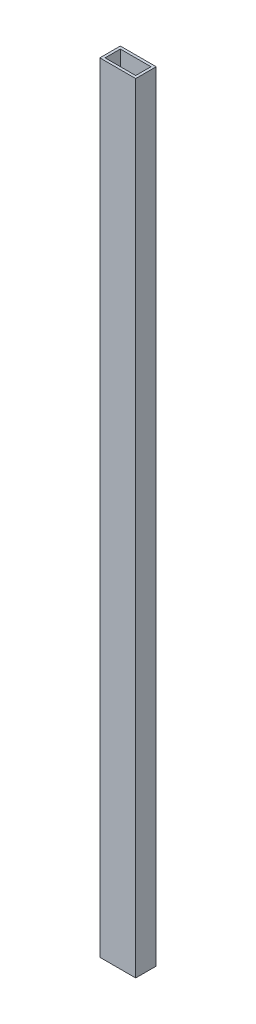
from build123d import *

# Parameters (mm, degrees)
SKETCH2_W           = 44.45
SKETCH2_H           = 25.4
BOSS_EXTRUDE2_DEPTH = 965.2
SKETCH3_W           = 37.973
SKETCH3_H           = 18.923
CUT_EXTRUDE1_DEPTH  = 1092.2


with BuildPart() as part:
    # Sketch2 → Boss-Extrude2 (new body)
    with BuildSketch(Plane(origin=(0, 0, 0), x_dir=(1, 0, 0), z_dir=(0, 1, 0))):
        with Locations((22.225, 12.7)):
            Rectangle(SKETCH2_W, SKETCH2_H)
    extrude(amount=BOSS_EXTRUDE2_DEPTH)

    # Sketch3 → Cut-Extrude1 (cut)
    with BuildSketch(Plane(origin=(0, 965.2, 0), x_dir=(1, 0, 0), z_dir=(0, 1, 0))):
        with Locations((22.225, 12.7)):
            Rectangle(SKETCH3_W, SKETCH3_H)
    extrude(amount=-CUT_EXTRUDE1_DEPTH, mode=Mode.SUBTRACT)


solid = part.part
